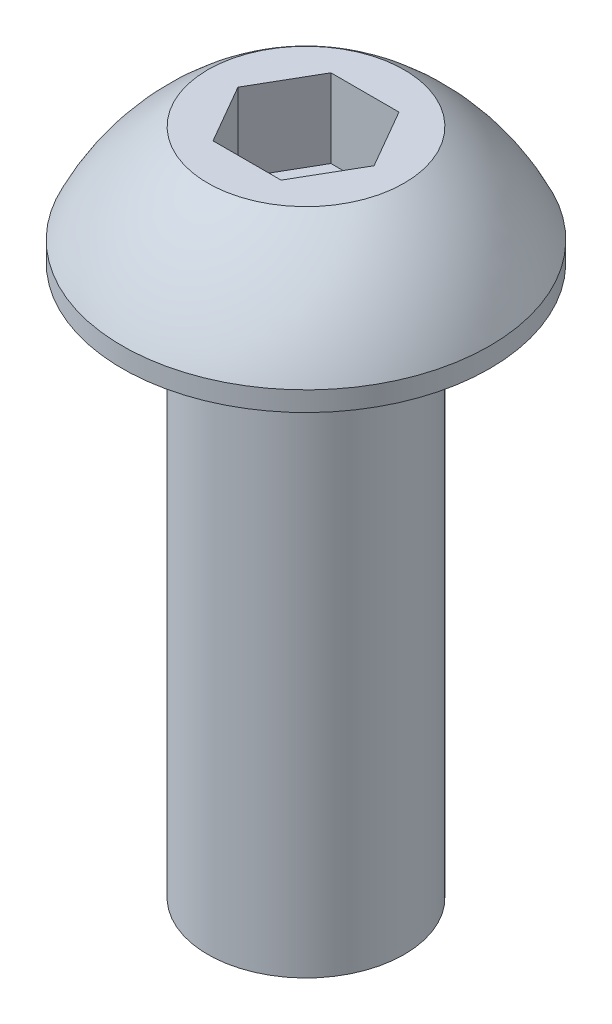
from build123d import *

# Parameters (mm, degrees)
CUT_EXTRUDE1_DEPTH = 2


with BuildPart() as part:
    # Sketch1 → Revolve1 (revolve)
    with BuildSketch(Plane.XY):
        with BuildLine():
            Line((2.5, 0), (4.675, 0))
            Line((4.675, 0), (4.675, 0.5))
            ThreePointArc((4.675, 0.5), (3.763510598, 1.90312922), (2.5, 3))
            Line((2.5, 3), (0, 3))
            Line((0, 3), (0, -14))
            Line((0, -14), (2.5, -14))
            Line((2.5, -14), (2.5, 0))
        make_face()
    revolve(axis=Axis((0, -14, 0), (0, 1, 0)))

    # Sketch2 → Cut-Extrude1 (cut)
    with BuildSketch(Plane(origin=(0, 3, 0), x_dir=(1, 0, 0), z_dir=(0, 1, 0))):
        Polygon((0.866025404, 1.5), (-0.866025404, 1.5), (-1.732050808, 0), (-0.866025404, -1.5), (0.866025404, -1.5), (1.732050808, 0), align=None)
    extrude(amount=-CUT_EXTRUDE1_DEPTH, mode=Mode.SUBTRACT)


solid = part.part
